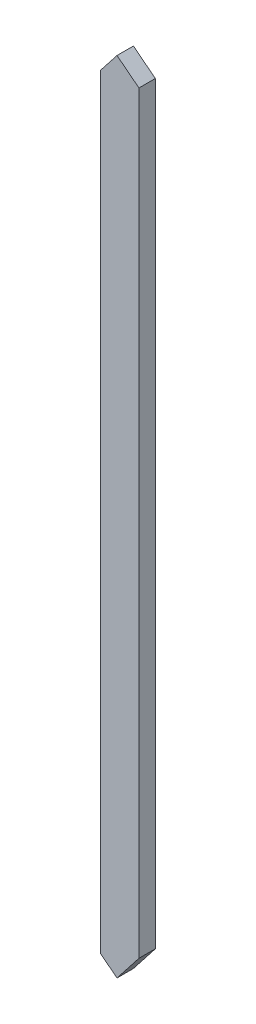
from build123d import *

# Parameters (mm, degrees)
SKETCH1_W           = 88.9
SKETCH1_H           = 38.1
BOSS_EXTRUDE1_DEPTH = 2032
CUT_EXTRUDE2_DEPTH  = 39.1
CUT_EXTRUDE3_DEPTH  = 39.1


with BuildPart() as part:
    # Sketch1 → Boss-Extrude1 (new body)
    with BuildSketch(Plane(origin=(0, 0, 0), x_dir=(1, 0, 0), z_dir=(0, 1, 0))):
        Rectangle(SKETCH1_W, SKETCH1_H)
    extrude(amount=BOSS_EXTRUDE1_DEPTH)

    # Sketch2 → Cut-Extrude2 (cut, through all)
    with BuildSketch(Plane.XY.offset(19.05)):
        Polygon((-44.45, 1806.041104583), (-6.454118941, 1854.591397047), (44.45, 1814.753390919), (44.45, 2032), (-44.45, 2032), align=None)
    extrude(amount=-CUT_EXTRUDE2_DEPTH, mode=Mode.SUBTRACT)

    # Sketch3 → Cut-Extrude3 (cut, through all)
    with BuildSketch(Plane.XY.offset(19.05)):
        Polygon((44.45, 65.04415198), (-6.454118941, 0), (-44.45, 29.735906916), (-64.239470553, 4.449361209), (31.244243748, -54.430099769), (82.106502152, 35.573845948), align=None)
    extrude(amount=-CUT_EXTRUDE3_DEPTH, mode=Mode.SUBTRACT)


solid = part.part
